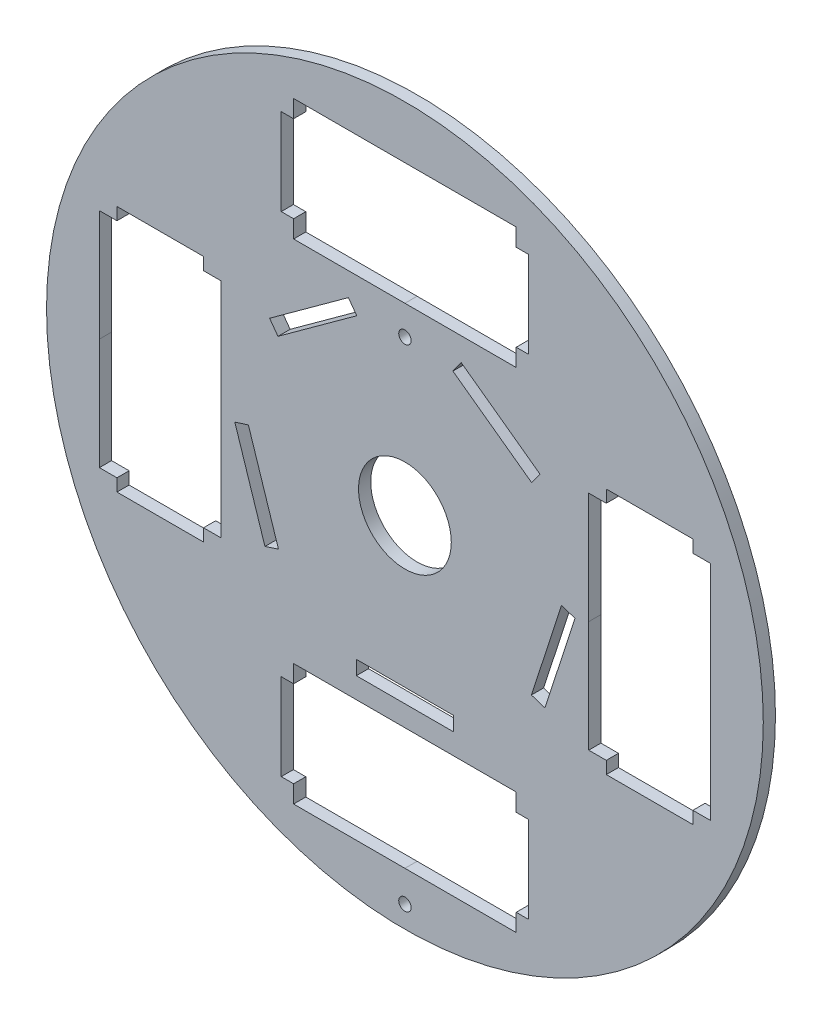
from build123d import *

# Parameters (mm, degrees)
MODEL_R             = 147.220888612
MODEL_R_2           = 2.54
MODEL_R_3           = 19.05
MODEL_W             = 40.000341048
MODEL_H             = 5.842
BOSS_EXTRUDE1_DEPTH = 5.0038


with BuildPart() as part:
    # Model → Boss-Extrude1 (new body)
    with BuildSketch(Plane.XY):
        with Locations((150.608180965, -149.916372011)):
            Circle(MODEL_R)
        with Locations((150.608180965, -288.178437552)):
            Circle(MODEL_R_2, mode=Mode.SUBTRACT)
        with Locations((150.608180965, -149.916372011)):
            Circle(MODEL_R_3, mode=Mode.SUBTRACT)
        with Locations((150.608395424, -86.435544776)):
            Circle(MODEL_R_2, mode=Mode.SUBTRACT)
        Polygon((75.097257942, -195.636586469), (75.097257942, -149.916586488), (75.097650189, -104.19658647), (67.880551818, -104.196555511), (67.880573609, -99.116555511), (32.320573609, -99.116402971), (32.320551818, -104.196402971), (25.103453446, -104.196372012), (25.103453446, -149.916371999), (25.103061199, -195.636372011), (32.32015957, -195.63640297), (32.320137779, -200.71640297), (67.880137779, -200.71655551), (67.88015957, -195.63655551), align=None, mode=Mode.SUBTRACT)
        with Locations((150.651713387, -213.962635212)):
            Rectangle(MODEL_W, MODEL_H, mode=Mode.SUBTRACT)
        Polygon((93.11237376, -189.673088704), (80.751588595, -151.630503696), (86.307660763, -149.825226415), (98.668445928, -187.867811423), align=None, mode=Mode.SUBTRACT)
        Polygon((95.030114956, -107.520111007), (127.391070645, -84.008500452), (130.824912089, -88.734777734), (98.4639564, -112.246388288), align=None, mode=Mode.SUBTRACT)
        Polygon((196.328395424, -225.427295034), (150.608395424, -225.427295034), (104.888395425, -225.426902787), (104.888364466, -232.644001159), (99.808364466, -232.643979367), (99.808211925, -268.203979367), (104.888211925, -268.204001158), (104.888180966, -275.42109953), (150.608180967, -275.42109953), (196.328180965, -275.421491778), (196.328211924, -268.204393406), (201.408211924, -268.204415197), (201.408364465, -232.644415198), (196.328364465, -232.644393406), align=None, mode=Mode.SUBTRACT)
        Polygon((104.887966507, -74.405448987), (150.607966472, -74.405448987), (196.327966506, -74.405841235), (196.327997465, -67.188742863), (201.407997465, -67.188764655), (201.408150006, -31.628764655), (196.328150006, -31.628742863), (196.328180965, -24.411644492), (150.608181003, -24.411644492), (104.888180965, -24.411252244), (104.888150006, -31.628350616), (99.808150007, -31.628328824), (99.807997466, -67.188328824), (104.887997466, -67.188350615), align=None, mode=Mode.SUBTRACT)
        Polygon((226.119103989, -104.196157552), (226.119103989, -149.916157498), (226.118711741, -195.636157551), (233.335810113, -195.63618851), (233.335788322, -200.71618851), (268.895788321, -200.716341051), (268.895810113, -195.636341051), (276.112908485, -195.63637201), (276.112908485, -149.916372061), (276.113300732, -104.196372011), (268.89620236, -104.196341052), (268.896224152, -99.116341052), (233.336224152, -99.116188511), (233.336202361, -104.196188511), align=None, mode=Mode.SUBTRACT)
        Polygon((173.754854348, -83.957325021), (206.115810037, -107.468935576), (202.681968593, -112.195212857), (170.321012904, -88.683602302), align=None, mode=Mode.SUBTRACT)
        Polygon((220.491677852, -151.547700109), (208.130892687, -189.590285117), (202.574820519, -187.785007836), (214.935605684, -149.742422828), align=None, mode=Mode.SUBTRACT)
    extrude(amount=BOSS_EXTRUDE1_DEPTH)


solid = part.part
